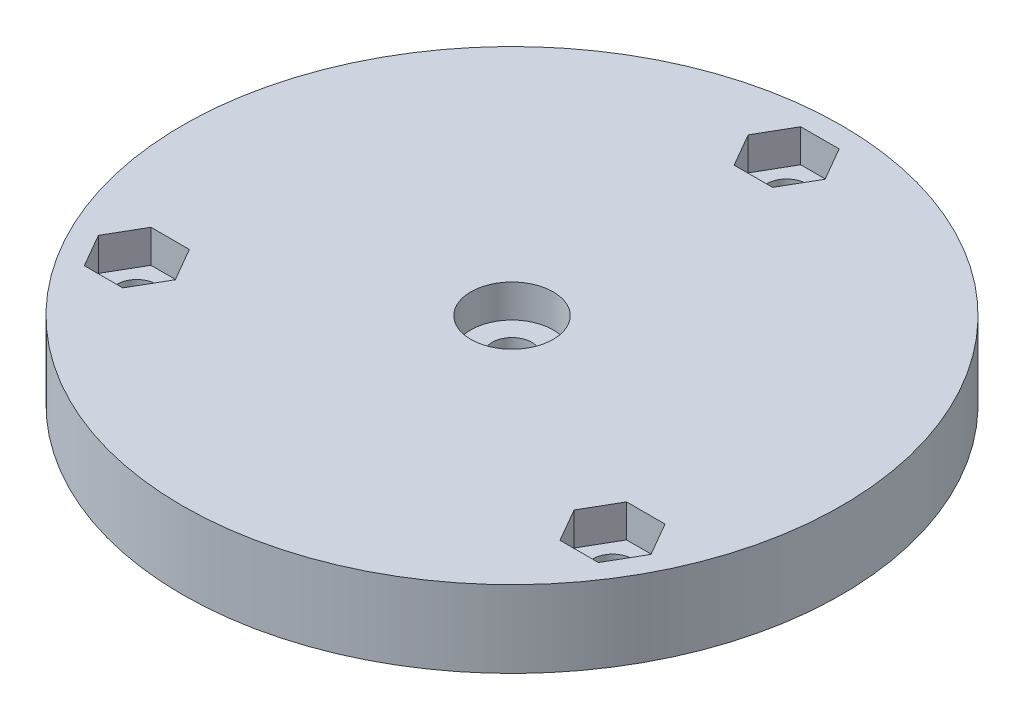
from build123d import *

# Parameters (mm, degrees)
SKETCH1_R           = 30
SKETCH1_R_2         = 1.8
BOSS_EXTRUDE1_DEPTH = 7
SKETCH2_R           = 3.75
CUT_EXTRUDE1_DEPTH  = 3


with BuildPart() as part:
    # Sketch1 → Boss-Extrude1 (new body)
    with BuildSketch(Plane(origin=(0, 0, 0), x_dir=(1, 0, 0), z_dir=(0, 1, 0))):
        Circle(SKETCH1_R)
        Circle(SKETCH1_R_2, mode=Mode.SUBTRACT)
        with Locations((0, 25)):
            Circle(SKETCH1_R_2, mode=Mode.SUBTRACT)
        with Locations((21.650635095, -12.5)):
            Circle(SKETCH1_R_2, mode=Mode.SUBTRACT)
        with Locations((-21.650635095, -12.5)):
            Circle(SKETCH1_R_2, mode=Mode.SUBTRACT)
    extrude(amount=BOSS_EXTRUDE1_DEPTH)

    # Sketch2 → Cut-Extrude1 (cut)
    with BuildSketch(Plane(origin=(0, 7, 0), x_dir=(1, 0, 0), z_dir=(0, 1, 0))):
        Circle(SKETCH2_R)
        Polygon((19.900635095, -15.531088913), (23.400635095, -15.531088913), (25.150635095, -12.5), (23.400635095, -9.468911087), (19.900635095, -9.468911087), (18.150635095, -12.5), align=None)
        Polygon((3.5, 25), (1.75, 28.031088913), (-1.75, 28.031088913), (-3.5, 25), (-1.75, 21.968911087), (1.75, 21.968911087), align=None)
        Polygon((-23.400635095, -9.468911087), (-25.150635095, -12.5), (-23.400635095, -15.531088913), (-19.900635095, -15.531088913), (-18.150635095, -12.5), (-19.900635095, -9.468911087), align=None)
    extrude(amount=-CUT_EXTRUDE1_DEPTH, mode=Mode.SUBTRACT)


solid = part.part
